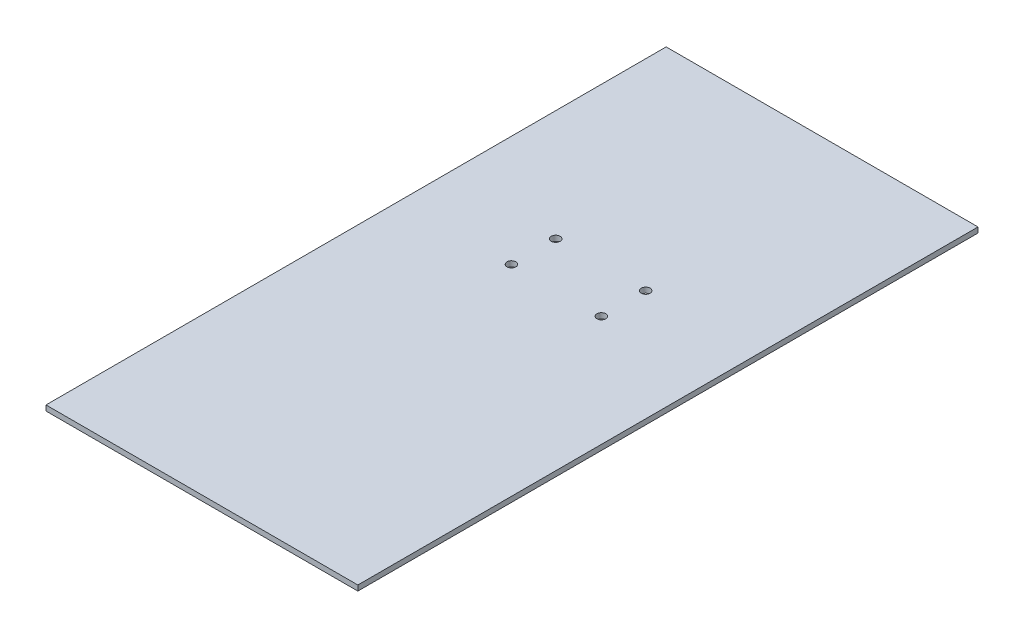
from build123d import *

# Parameters (mm, degrees)
SKETCH1_W                 = 176
SKETCH1_H                 = 350
BOSS_EXTRUDE1_DEPTH       = 3
F_5_0MM_DOWEL_HOLE1_D     = 5
F_5_0MM_DOWEL_HOLE1_DEPTH = 3


with BuildPart() as part:
    # Sketch1 → Boss-Extrude1 (new body)
    with BuildSketch(Plane(origin=(0, 0, 0), x_dir=(1, 0, 0), z_dir=(0, 1, 0))):
        with Locations((88, 175)):
            Rectangle(SKETCH1_W, SKETCH1_H)
    extrude(amount=BOSS_EXTRUDE1_DEPTH)

    # Ø5.0mm Dowel Hole1
    with Locations(Plane(origin=(0, 0, 0), x_dir=(-1, 0, 0), z_dir=(0, -1, 0))):
        with Locations((-113.399603526, 225.06), (-113.399603526, 200.06), (-62.62470798, 225.06), (-62.62470798, 200.06)):
            Hole(F_5_0MM_DOWEL_HOLE1_D / 2, depth=F_5_0MM_DOWEL_HOLE1_DEPTH)


solid = part.part
